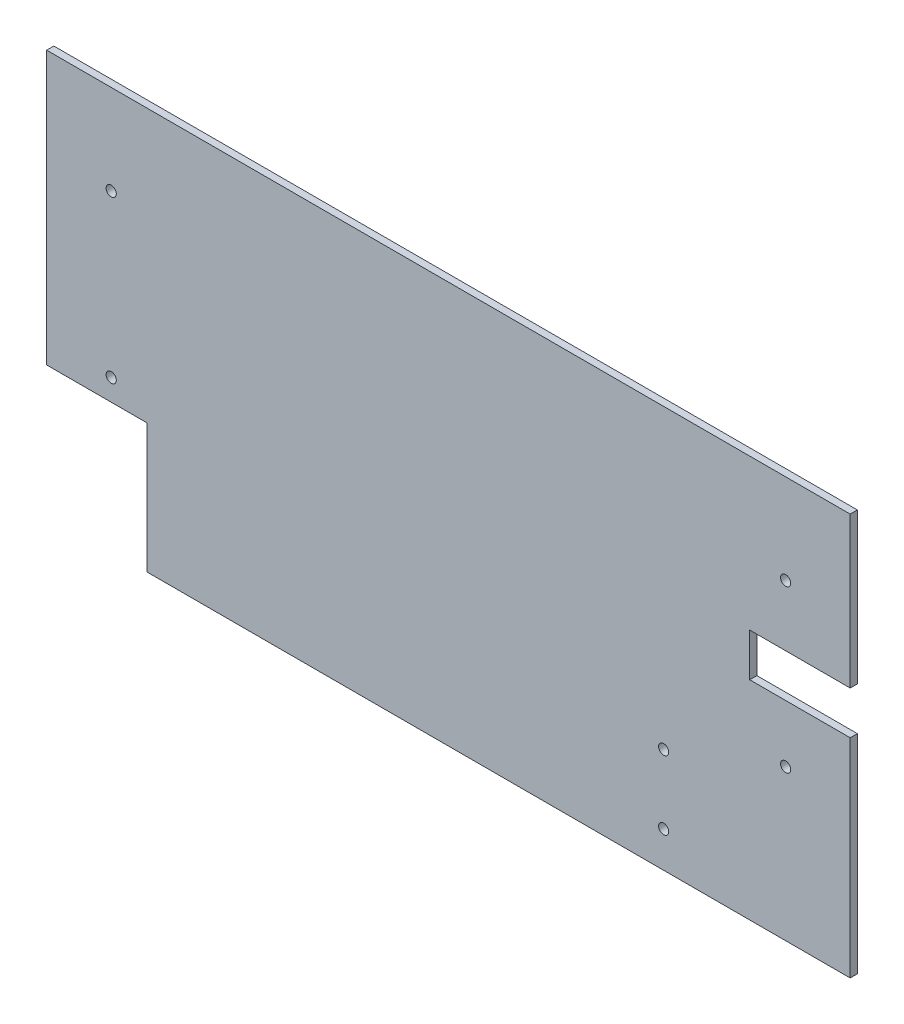
from build123d import *

# Parameters (mm, degrees)
SKETCH1_R           = 2.25
BOSS_EXTRUDE1_DEPTH = 3.175


with BuildPart() as part:
    # Sketch1 → Boss-Extrude1 (new body)
    with BuildSketch(Plane.XY):
        Polygon((-133.35, -88.9), (177.8, -88.9), (177.8, 3.175), (133.35, 3.175), (133.35, 22.225), (177.8, 22.225), (177.8, 88.9), (-177.8, 88.9), (-177.8, -31.75), (-133.35, -31.75), align=None)
        with Locations((-149.225, -22.225)):
            Circle(SKETCH1_R, mode=Mode.SUBTRACT)
        with Locations((95.25, -73.025)):
            Circle(SKETCH1_R, mode=Mode.SUBTRACT)
        with Locations((95.25, -42.545)):
            Circle(SKETCH1_R, mode=Mode.SUBTRACT)
        with Locations((149.225, -22.225)):
            Circle(SKETCH1_R, mode=Mode.SUBTRACT)
        with Locations((-149.225, 49.2125)):
            Circle(SKETCH1_R, mode=Mode.SUBTRACT)
        with Locations((149.225, 49.2125)):
            Circle(SKETCH1_R, mode=Mode.SUBTRACT)
    extrude(amount=-BOSS_EXTRUDE1_DEPTH)


solid = part.part
